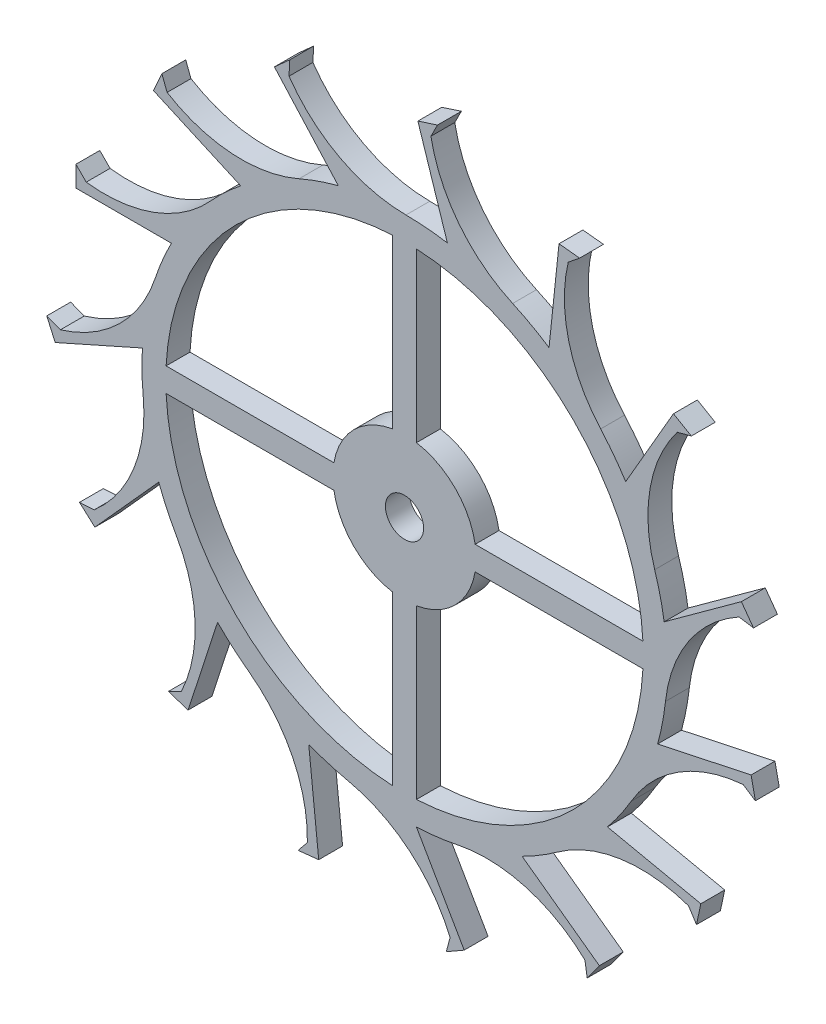
from build123d import *

# Parameters (mm, degrees)
CROQUIS1_R              = 2.75
CROQUIS1_R_2            = 0.2
SALIENTE_EXTRUIR1_DEPTH = 0.25
SALIENTE_EXTRUIR2_DEPTH = 0.25
MATRIZC1_COUNT          = 15


with BuildPart() as part:
    # Croquis1 → Saliente-Extruir1 (new body)
    with BuildSketch(Plane.XY):
        Circle(CROQUIS1_R)
        Circle(CROQUIS1_R_2, mode=Mode.SUBTRACT)
        with BuildLine():
            Line((0.125, -2.496873044), (0.125, -0.739509973))
            ThreePointArc((0.125, -0.739509973), (0.530330086, -0.530330086), (0.739509973, -0.125))
            Line((0.739509973, -0.125), (2.496873044, -0.125))
            ThreePointArc((2.496873044, -0.125), (1.767766953, -1.767766953), (0.125, -2.496873044))
        make_face(mode=Mode.SUBTRACT)
        with BuildLine():
            ThreePointArc((-0.125, 2.496873044), (-1.767766953, 1.767766953), (-2.496873044, 0.125))
            Line((-2.496873044, 0.125), (-0.739509973, 0.125))
            ThreePointArc((-0.739509973, 0.125), (-0.530330086, 0.530330086), (-0.125, 0.739509973))
            Line((-0.125, 0.739509973), (-0.125, 2.496873044))
        make_face(mode=Mode.SUBTRACT)
        with BuildLine():
            Line((0.739509973, 0.125), (2.496873044, 0.125))
            ThreePointArc((2.496873044, 0.125), (1.767766953, 1.767766953), (0.125, 2.496873044))
            Line((0.125, 2.496873044), (0.125, 0.739509973))
            ThreePointArc((0.125, 0.739509973), (0.530330086, 0.530330086), (0.739509973, 0.125))
        make_face(mode=Mode.SUBTRACT)
        with BuildLine():
            Line((-2.496873044, -0.125), (-0.739509973, -0.125))
            ThreePointArc((-0.739509973, -0.125), (-0.530330086, -0.530330086), (-0.125, -0.739509973))
            Line((-0.125, -0.739509973), (-0.125, -2.496873044))
            ThreePointArc((-0.125, -2.496873044), (-1.767766953, -1.767766953), (-2.496873044, -0.125))
        make_face(mode=Mode.SUBTRACT)
    extrude(amount=SALIENTE_EXTRUIR1_DEPTH)

    # Croquis2 → Saliente-Extruir2 (add)
    with BuildSketch(Plane(origin=(0, 0, 0), x_dir=(-1, 0, 0), z_dir=(0, 0, -1))):
        with BuildLine():
            Line((-0.625, -3.613183026), (-0.4375, -3.721436201))
            Line((-0.4375, -3.721436201), (-0.477123412, -3.573559614))
            ThreePointArc((-0.477123412, -3.573559614), (-0.053677893, -2.999971472), (0.586755021, -2.686674254))
            ThreePointArc((0.586755021, -2.686674254), (0.232849703, -2.74012427), (-0.125, -2.747157622))
            Line((-0.125, -2.747157622), (-0.625, -3.613183026))
        make_face()
    saliente_extruir2 = extrude(amount=-SALIENTE_EXTRUIR2_DEPTH)

    # MatrizC1: Saliente-Extruir2 ×15 about axis
    matrizc1_axis = Axis((0, 0, 0), (0, 0, 1))
    for i in range(1, MATRIZC1_COUNT):
        add(saliente_extruir2.rotate(matrizc1_axis, i * 360 / MATRIZC1_COUNT))


solid = part.part
